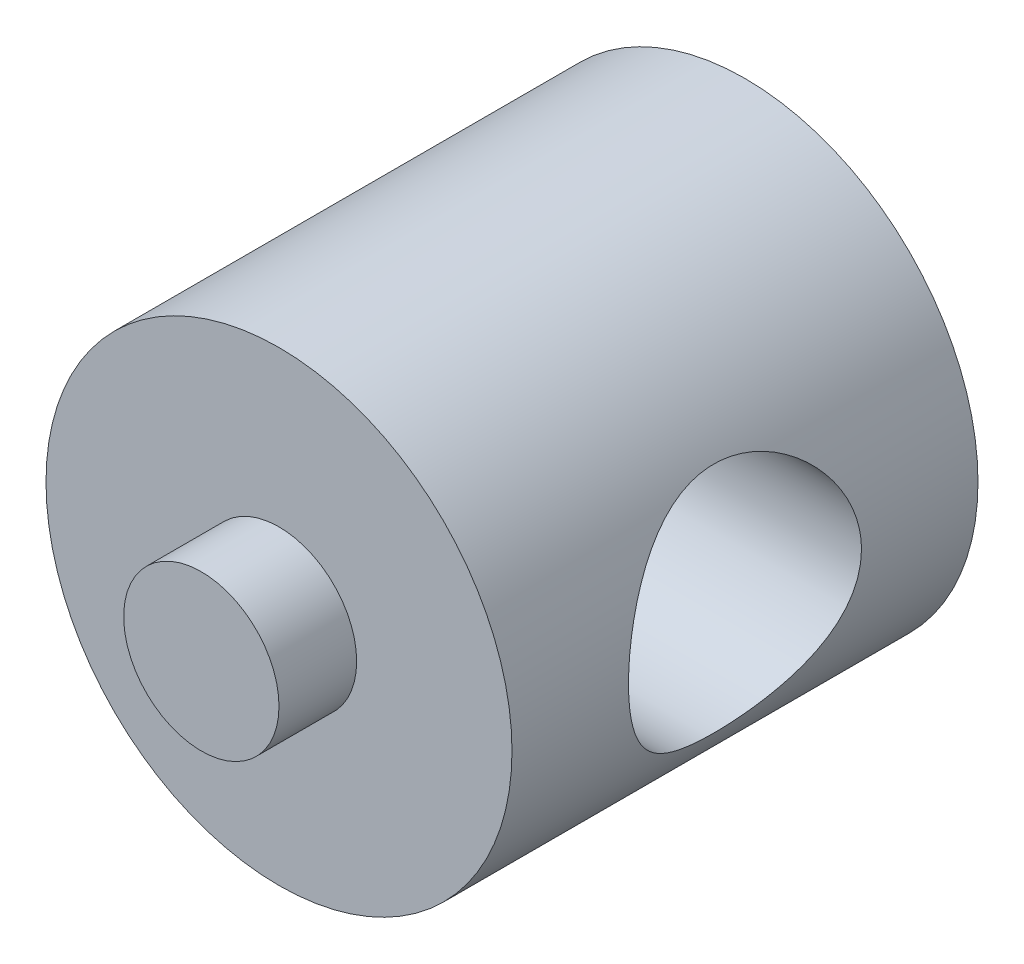
from build123d import *

# Parameters (mm, degrees)
SKETCH1_R               = 9.525
BOSS_EXTRUDE1_DEPTH     = 9.525
SKETCH2_R               = 3.175
BOSS_EXTRUDE2_DEPTH     = 12.7
SKETCH3_R               = 4.7625
CUT_EXTRUDE1_DEPTH      = 10.525
CUT_EXTRUDE1_DEPTH_BACK = 10.525


with BuildPart() as part:
    # Sketch1 → Boss-Extrude1 (new body, symmetric)
    with BuildSketch(Plane.XY):
        Circle(SKETCH1_R)
    extrude(amount=BOSS_EXTRUDE1_DEPTH, both=True)

    # Sketch2 → Boss-Extrude2 (add, symmetric)
    with BuildSketch(Plane.XY):
        Circle(SKETCH2_R)
    extrude(amount=BOSS_EXTRUDE2_DEPTH, both=True)

    # Sketch3 → Cut-Extrude1 (cut, two sides)
    with BuildSketch(Plane(origin=(0, 0, 0), x_dir=(0, 0, -1), z_dir=(1, 0, 0))) as cut_extrude1_sk:
        Circle(SKETCH3_R)
    extrude(amount=CUT_EXTRUDE1_DEPTH, mode=Mode.SUBTRACT)
    extrude(cut_extrude1_sk.sketch, amount=-CUT_EXTRUDE1_DEPTH_BACK, mode=Mode.SUBTRACT)


solid = part.part
